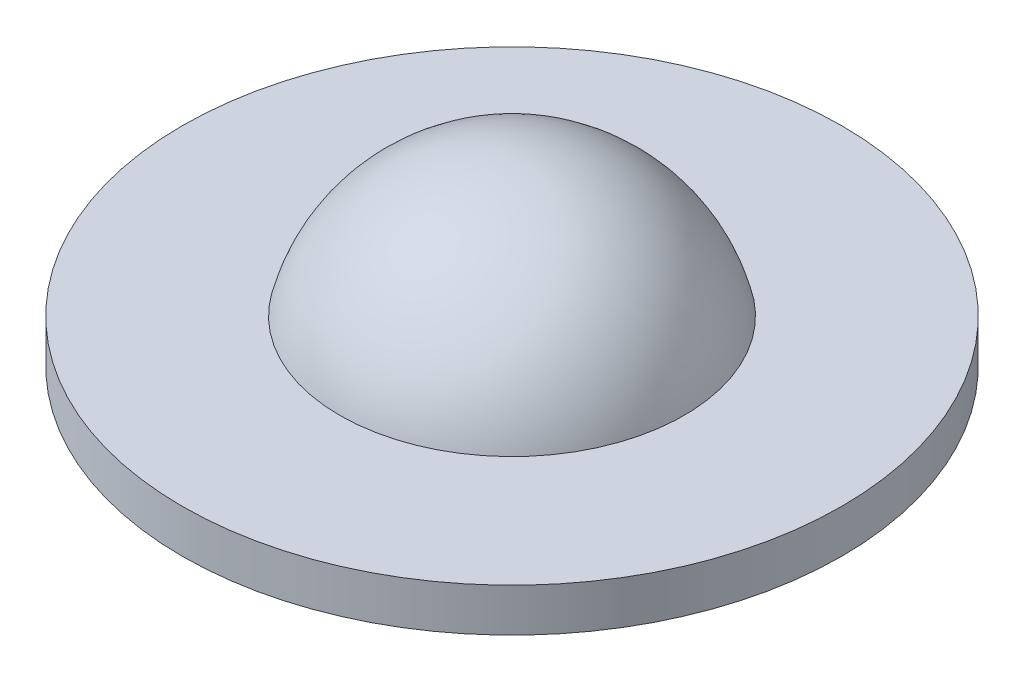
from build123d import *


with BuildPart() as part:
    # Sketch1 → Revolve1 (revolve)
    with BuildSketch(Plane(origin=(0, 0, 0), x_dir=(0, 0, -1), z_dir=(1, 0, 0))):
        with BuildLine():
            Line((-7.936641236, -0.116756757), (-22.86, -0.116756757))
            Line((-22.86, -0.116756757), (-22.86, 2.883243243))
            Line((-22.86, 2.883243243), (-11.938, 2.883243243))
            ThreePointArc((-11.938, 2.883243243), (-7.596680986, 9.649838009), (0, 12.281243243))
            Line((0, 12.281243243), (0, 0))
            Line((0, 0), (0, -7.9375))
            ThreePointArc((0, -7.9375), (-5.5712274, -5.653789128), (-7.936641236, -0.116756757))
        make_face()
    revolve(axis=Axis((0, -19.657005973, 0), (0, -1, 0)))


solid = part.part
